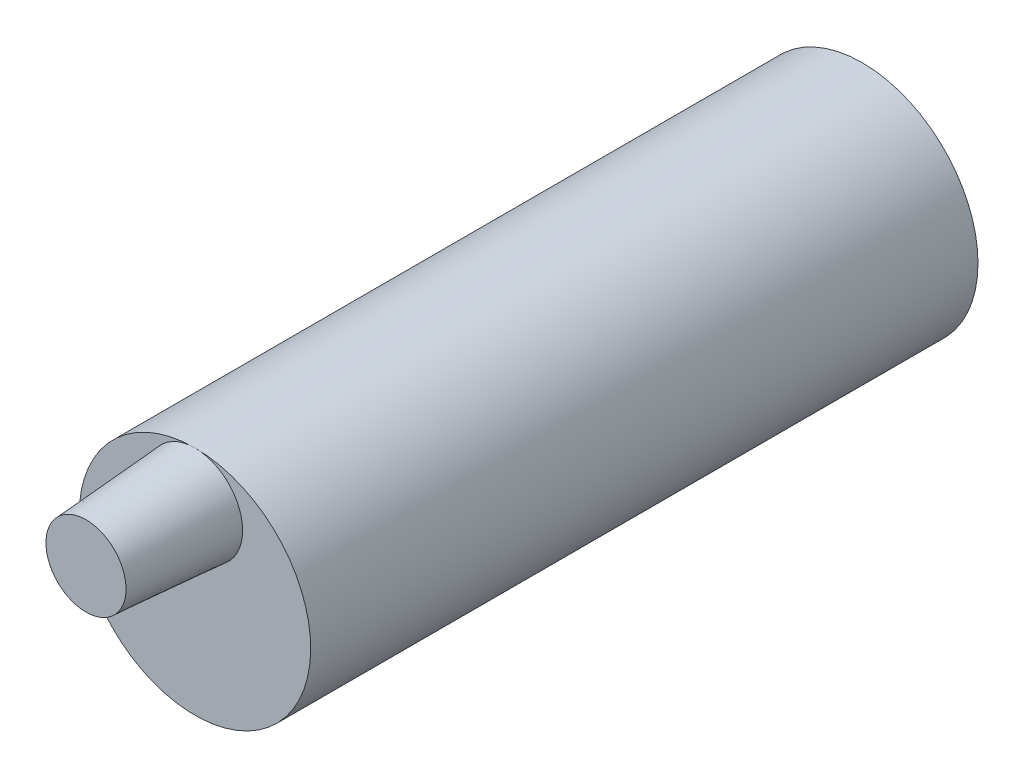
from build123d import *

# Parameters (mm, degrees)
SKETCH1_R           = 8.5
BOSS_EXTRUDE1_DEPTH = 49
SKETCH2_R           = 3.5
BOSS_EXTRUDE2_DEPTH = 8
BOSS_EXTRUDE2_TAPER = 4


with BuildPart() as part:
    # Sketch1 → Boss-Extrude1 (new body)
    with BuildSketch(Plane.XY):
        Circle(SKETCH1_R)
    extrude(amount=BOSS_EXTRUDE1_DEPTH)

    # Sketch2 → Boss-Extrude2 (add)
    with BuildSketch(Plane.XY.offset(49)):
        with Locations((0, 5)):
            Circle(SKETCH2_R)
    extrude(amount=BOSS_EXTRUDE2_DEPTH, taper=BOSS_EXTRUDE2_TAPER)


solid = part.part
